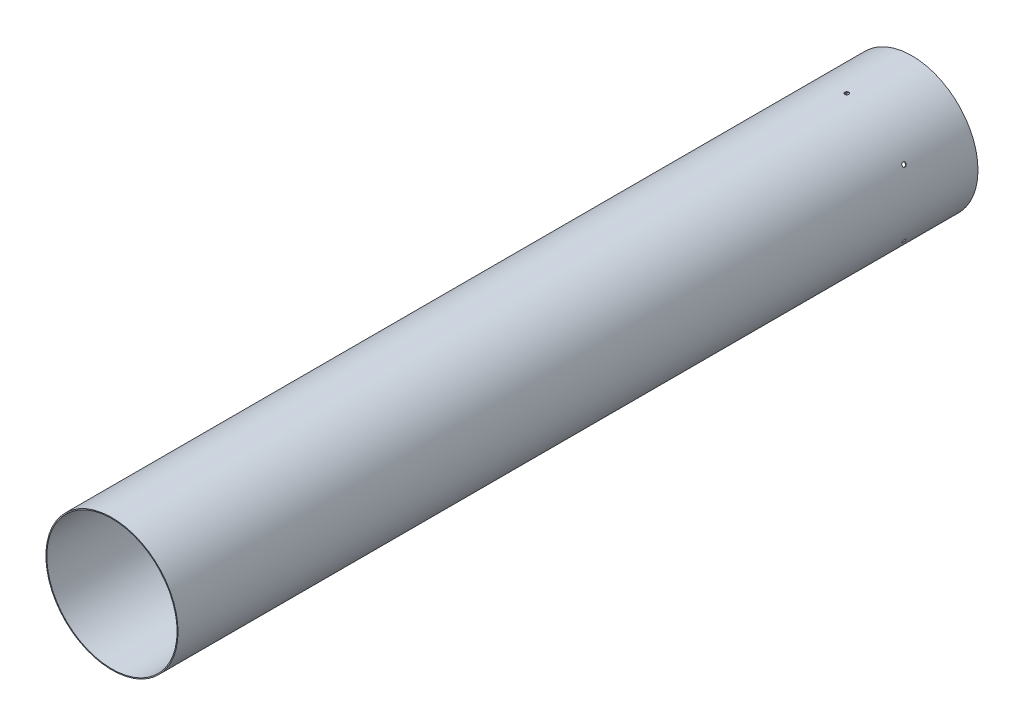
from build123d import *

# Parameters (mm, degrees)
SKETCH1_R                         = 80.518
SKETCH1_R_2                       = 79.375
BOSS_EXTRUDE1_DEPTH               = 974.725
F_10_0_1935_DIAMETER_HOLE1_REACH  = 993.214
F_10_0_1935_DIAMETER_HOLE1_BORE_R = 2.45745
CIRPATTERN1_COUNT                 = 6


with BuildPart() as part:
    # Sketch1 → Boss-Extrude1 (new body)
    with BuildSketch(Plane.XY):
        with Locations(Location((0, 0, 0), (0, 0, 180))):
            Circle(SKETCH1_R)
        with Locations(Location((0, 0, 0), (0, 0, 180))):
            Circle(SKETCH1_R_2, mode=Mode.SUBTRACT)
    extrude(amount=BOSS_EXTRUDE1_DEPTH)

    # #10 (0.1935) Diameter Hole1 bore → #10 (0.1935) Diameter Hole1 (cut, up to next)
    with BuildSketch(Plane(origin=(0, 80.518, 0), x_dir=(1, 0, 0), z_dir=(0, 1, 0)), mode=Mode.PRIVATE) as f_10_0_1935_diameter_hole1_sk1:
        with Locations((0, -79.375)):
            Circle(F_10_0_1935_DIAMETER_HOLE1_BORE_R)
    f_10_0_1935_diameter_hole1_tool1 = extrude(f_10_0_1935_diameter_hole1_sk1.sketch, amount=-F_10_0_1935_DIAMETER_HOLE1_REACH, mode=Mode.PRIVATE) & part.part
    f_10_0_1935_diameter_hole1 = f_10_0_1935_diameter_hole1_tool1.solids().sort_by_distance((0, 80.518, 79.375))[0]
    add(f_10_0_1935_diameter_hole1, mode=Mode.SUBTRACT)

    # CirPattern1: #10 (0.1935) Diameter Hole1 ×6 about axis
    cirpattern1_axis = Axis((0, 0, 0), (0, 0, 1))
    for i in range(1, CIRPATTERN1_COUNT):
        add(f_10_0_1935_diameter_hole1.rotate(cirpattern1_axis, i * 360 / CIRPATTERN1_COUNT), mode=Mode.SUBTRACT)


solid = part.part
